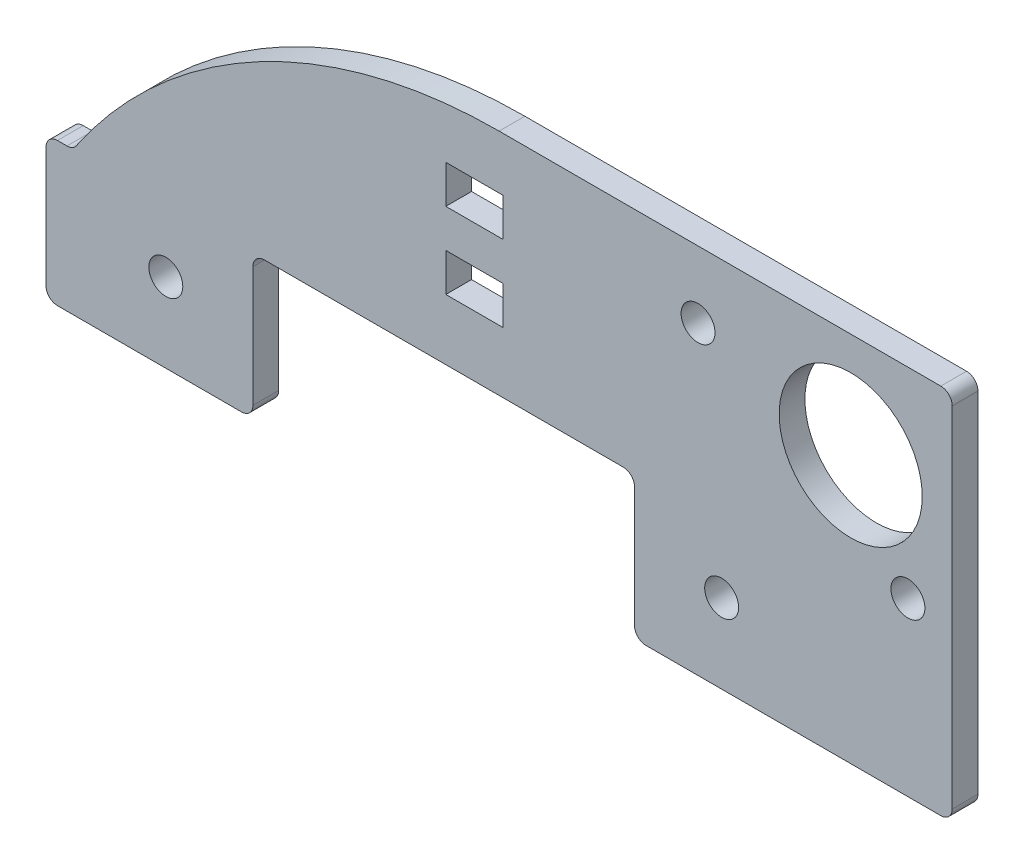
from build123d import *

# Parameters (mm, degrees)
SKETCH1_R           = 4.7625
SKETCH1_R_2         = 1.1303
BOSS_EXTRUDE1_DEPTH = 1.7145
SKETCH2_W           = 3.81
SKETCH2_H           = 2.54
CUT_EXTRUDE1_DEPTH  = 1.7145
SKETCH3_W           = 25.4
SKETCH3_H           = 9.525
CUT_EXTRUDE2_DEPTH  = 1.7145
FILLET1_R           = 0.762
FILLET2_R           = 0.762


with BuildPart() as part:
    # Sketch1 → Boss-Extrude1 (new body)
    with BuildSketch(Plane.XY):
        with BuildLine():
            Line((-30.1625, 9.245), (30.1625, 9.245))
            Line((30.1625, 9.245), (30.1625, 34.01))
            Line((30.1625, 34.01), (0, 34.01))
            ThreePointArc((0, 34.01), (-16.098329106, 29.958703243), (-28.361368091, 18.77))
            Line((-28.361368091, 18.77), (-30.1625, 18.77))
            Line((-30.1625, 18.77), (-30.1625, 9.245))
        make_face()
        with Locations((23.402088835, 27.025)):
            Circle(SKETCH1_R, mode=Mode.SUBTRACT)
        with Locations((-22.1869, 14.5155)):
            Circle(SKETCH1_R_2, mode=Mode.SUBTRACT)
        with Locations((14.813099914, 14.5155)):
            Circle(SKETCH1_R_2, mode=Mode.SUBTRACT)
        with Locations((27.212088835, 20.675)):
            Circle(SKETCH1_R_2, mode=Mode.SUBTRACT)
        with Locations((13.242088835, 29.565)):
            Circle(SKETCH1_R_2, mode=Mode.SUBTRACT)
    extrude(amount=BOSS_EXTRUDE1_DEPTH)

    # Sketch2 → Cut-Extrude1 (cut)
    with BuildSketch(Plane.XY.offset(1.7145)):
        with Locations((-1.644140797, 29.166672544)):
            Rectangle(SKETCH2_W, SKETCH2_H)
        with Locations((-1.644140797, 24.086672544)):
            Rectangle(SKETCH2_W, SKETCH2_H)
    extrude(amount=-CUT_EXTRUDE1_DEPTH, mode=Mode.SUBTRACT)

    # Sketch3 → Cut-Extrude2 (cut)
    with BuildSketch(Plane.XY.offset(1.7145)):
        with Locations((-3.686900043, 14.0075)):
            Rectangle(SKETCH3_W, SKETCH3_H)
    extrude(amount=-CUT_EXTRUDE2_DEPTH, mode=Mode.SUBTRACT)

    # Fillet1
    fillet1_edges = [part.edges().sort_by_distance(p)[0] for p in [
        (-28.361368091, 18.77, 0.85725),
        (30.1625, 34.01, 0.85725),
        (30.1625, 9.245, 0.85725),
        (-30.1625, 9.245, 0.85725),
        (-30.1625, 18.77, 0.85725),
        (-16.386900043, 9.245, 0.85725),
        (9.013099957, 9.245, 0.85725),
    ]]
    fillet(fillet1_edges, radius=FILLET1_R)

    # Fillet2
    fillet2_edges = [part.edges().sort_by_distance(p)[0] for p in [
        (-16.386900043, 18.77, 0.85725),
        (9.013099957, 18.77, 0.85725),
    ]]
    fillet(fillet2_edges, radius=FILLET2_R)


solid = part.part
